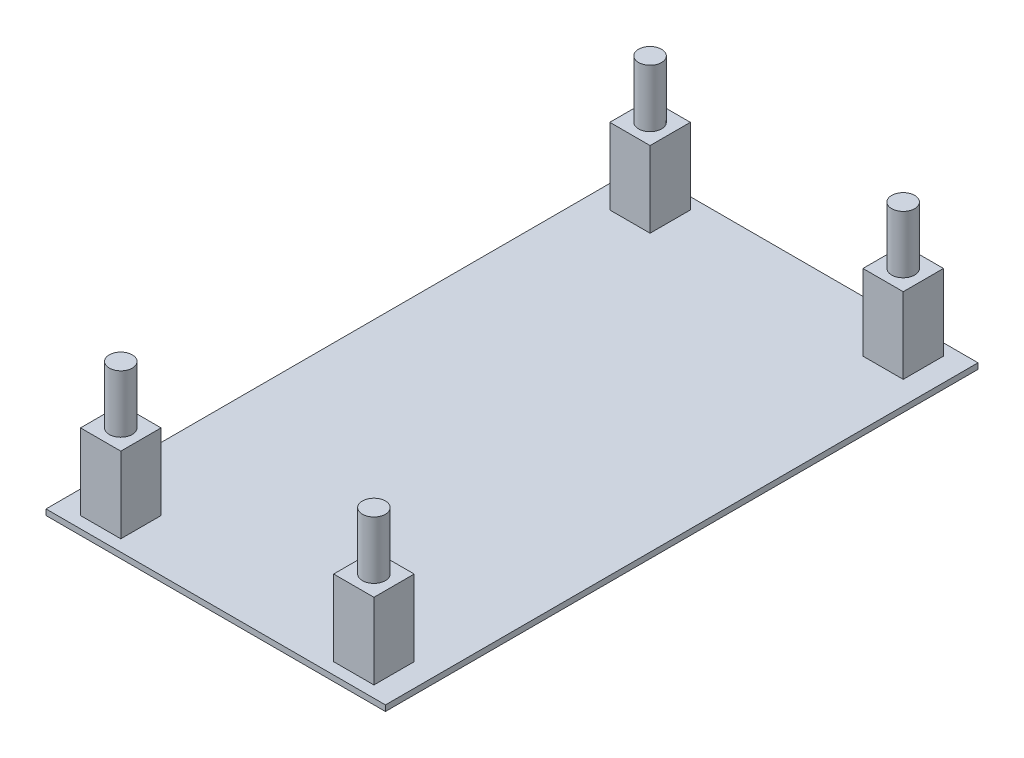
from build123d import *

# Parameters (mm, degrees)
SKETCH_1_W          = 140
SKETCH_1_H          = 75
EXTRUDE_1_DEPTH     = 61
SHELL_1_T           = -1.5
SKETCH_3_W          = 130
SKETCH_3_H          = 65
CUT_EXTRUDE_1_DEPTH = 117.308601118
SKETCH_4_W          = 137
SKETCH_4_H          = 2.6
SKETCH_4_H_2        = 3.3
EXTRUDE_2_DEPTH     = 5
SKETCH_5_W          = 2.4
SKETCH_5_H          = 69.4
EXTRUDE_3_DEPTH     = 5
SKETCH_20_W         = 3.5
SKETCH_20_H         = 3.5
EXTRUDE_4_DEPTH     = 6.6
SKETCH_21_R         = 1
EXTRUDE_5_DEPTH     = 5
SKETCH_22_W         = 140
SKETCH_22_H         = 61
SKETCH_22_W_2       = 29.5
SKETCH_22_H_2       = 51.5
CUT_EXTRUDE_4_DEPTH = 100
SKETCH_23_W         = 29.5
SKETCH_23_H         = 51.5
CUT_EXTRUDE_5_DEPTH = 1


with BuildPart() as part:
    # 草图1 → 凸台-拉伸1 (new body)
    with BuildSketch(Plane.XY):
        with Locations((19.248188406, -5.412137681)):
            Rectangle(SKETCH_1_W, SKETCH_1_H)
    extrude(amount=EXTRUDE_1_DEPTH)

    # 抽壳1
    shell_1_openings = [part.faces().sort_by_distance(p)[0] for p in [
        (19.248188406, -5.412137681, 61),
    ]]
    offset(amount=SHELL_1_T, openings=shell_1_openings, kind=Kind.INTERSECTION)

    # 草图3 → 切除-拉伸1 (cut, through all)
    with BuildSketch(Plane(origin=(0, 0, 0), x_dir=(-1, 0, 0), z_dir=(0, 0, -1))):
        with Locations((-19.248188406, -5.412137681)):
            Rectangle(SKETCH_3_W, SKETCH_3_H)
    extrude(amount=-CUT_EXTRUDE_1_DEPTH, mode=Mode.SUBTRACT)

    # 草图4 → 凸台-拉伸2 (add)
    with BuildSketch(Plane.XY.offset(1.5)):
        with Locations((19.248188406, -40.112137681)):
            Rectangle(SKETCH_4_W, SKETCH_4_H)
        with Locations((19.248188406, 28.937862319)):
            Rectangle(SKETCH_4_W, SKETCH_4_H_2)
    extrude(amount=EXTRUDE_2_DEPTH)

    # 草图5 → 凸台-拉伸3 (add)
    with BuildSketch(Plane.XY.offset(1.5)):
        with Locations((-48.051811594, -4.112137681)):
            Rectangle(SKETCH_5_W, SKETCH_5_H)
        with Locations((86.548188406, -4.112137681)):
            Rectangle(SKETCH_5_W, SKETCH_5_H)
    extrude(amount=EXTRUDE_3_DEPTH)

    # 草图20 → 凸台-拉伸4 (add)
    with BuildSketch(Plane(origin=(0, -41.412137681, 0), x_dir=(1, 0, 0), z_dir=(0, 1, 0))):
        with Locations((1.25, -55.75)):
            Rectangle(SKETCH_20_W, SKETCH_20_H)
        with Locations((1.25, -9.75)):
            Rectangle(SKETCH_20_W, SKETCH_20_H)
        with Locations((23.25, -9.75)):
            Rectangle(SKETCH_20_W, SKETCH_20_H)
        with Locations((23.25, -55.75)):
            Rectangle(SKETCH_20_W, SKETCH_20_H)
    extrude(amount=EXTRUDE_4_DEPTH)

    # 草图21 → 凸台-拉伸5 (add)
    with BuildSketch(Plane(origin=(0, -34.812137681, 0), x_dir=(1, 0, 0), z_dir=(0, 1, 0))):
        with Locations(Location((1.25, -55.75, 0), (0, 0, 270))):
            Circle(SKETCH_21_R)
        with Locations(Location((1.25, -9.75, 0), (0, 0, 270))):
            Circle(SKETCH_21_R)
        with Locations(Location((23.25, -9.75, 0), (0, 0, 270))):
            Circle(SKETCH_21_R)
        with Locations(Location((23.25, -55.75, 0), (0, 0, 270))):
            Circle(SKETCH_21_R)
    extrude(amount=EXTRUDE_5_DEPTH)

    # 草图22 → 切除-拉伸4 (cut, symmetric)
    with BuildSketch(Plane(origin=(0, -41.412137681, 0), x_dir=(1, 0, 0), z_dir=(0, 1, 0))):
        with Locations((19.248188406, -30.5)):
            Rectangle(SKETCH_22_W, SKETCH_22_H)
        with Locations((12.25, -32.75)):
            Rectangle(SKETCH_22_W_2, SKETCH_22_H_2, mode=Mode.SUBTRACT)
    extrude(amount=CUT_EXTRUDE_4_DEPTH, both=True, mode=Mode.SUBTRACT)


with BuildPart() as cut_extrude_4_kept_piece:
    # of the separate pieces the step leaves, the one the design keeps (cut_extrude_4_pieces_kept)
    add(part.part.solids().sort_by_distance((27, -42.912137681, 7))[0])

    # 草图23 → 切除-拉伸5 (cut)
    with BuildSketch(Plane.XZ.offset(42.912137681)):
        with Locations((12.25, 32.75)):
            Rectangle(SKETCH_23_W, SKETCH_23_H)
    extrude(amount=-CUT_EXTRUDE_5_DEPTH, mode=Mode.SUBTRACT)


solid = cut_extrude_4_kept_piece.part
